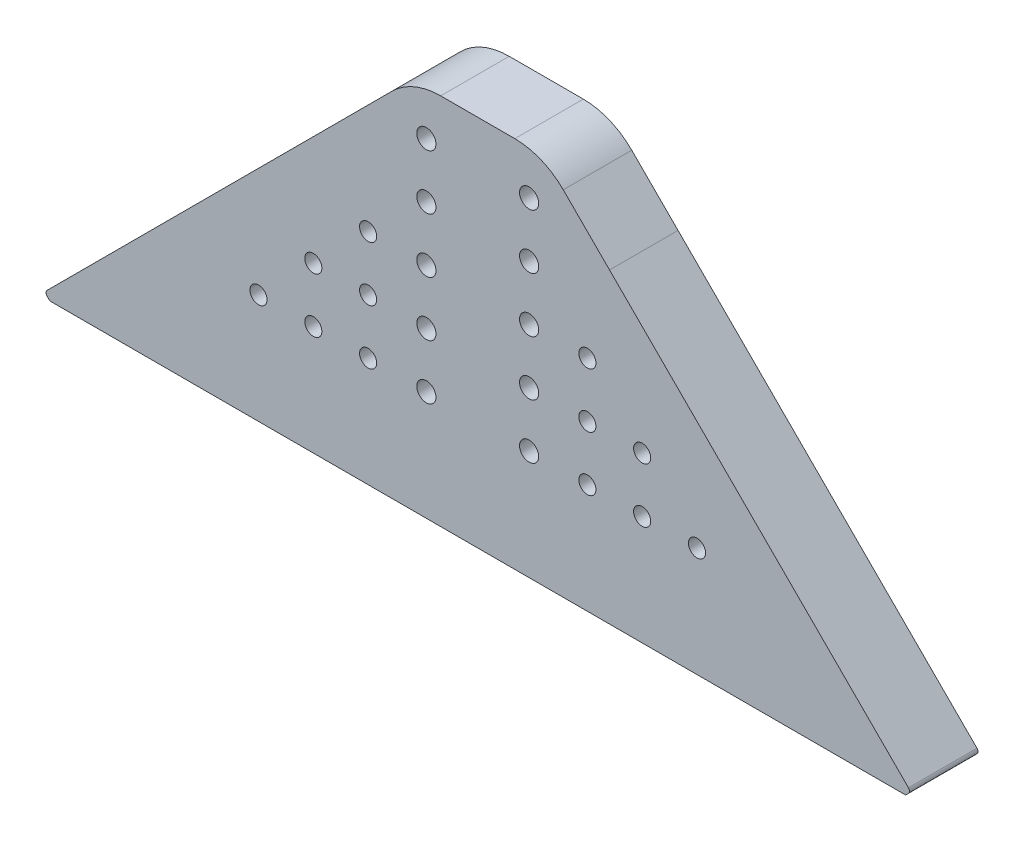
from build123d import *

# Parameters (mm, degrees)
SKETCH_3_R      = 1.25
SKETCH_3_R_2    = 1.4
EXTRUDE_2_DEPTH = 10


with BuildPart() as part:
    # 草图3 → 凸台-拉伸2 (new body)
    with BuildSketch(Plane.XY):
        with BuildLine():
            Line((1203.23159256, 480.404853327), (1082.731592366, 480.404853327))
            Line((1082.731592366, 480.404853327), (1082.310142824, 480.826300075))
            ThreePointArc((1082.310142824, 480.826300075), (1082.163698991, 481.179854306), (1082.310145601, 481.533406638))
            Line((1082.310145601, 481.533406638), (1132.702661596, 531.925922701))
            ThreePointArc((1132.702661596, 531.925922701), (1135.946895085, 534.093650218), (1139.773729412, 534.854854894))
            Line((1139.773729412, 534.854854894), (1150.589455978, 534.854854894))
            ThreePointArc((1150.589455978, 534.854854894), (1154.416289827, 534.093650416), (1157.660523063, 531.925923433))
            Line((1157.660523063, 531.925923433), (1164.418316344, 525.168131543))
            Line((1164.418316344, 525.168131543), (1208.053038819, 481.533406638))
            ThreePointArc((1208.053038819, 481.533406638), (1208.199485429, 481.179853247), (1208.053038819, 480.826299856))
            Line((1208.053038819, 480.826299856), (1207.631592536, 480.404853327))
            Line((1207.631592536, 480.404853327), (1203.23159256, 480.404853327))
        make_face()
        with Locations((1113.18159221, 496.404853247)):
            Circle(SKETCH_3_R, mode=Mode.SUBTRACT)
        with Locations((1121.18159221, 496.404853247)):
            Circle(SKETCH_3_R, mode=Mode.SUBTRACT)
        with Locations((1129.18159221, 512.404853247)):
            Circle(SKETCH_3_R, mode=Mode.SUBTRACT)
        with Locations((1129.18159221, 504.404853247)):
            Circle(SKETCH_3_R, mode=Mode.SUBTRACT)
        with Locations((1129.18159221, 496.404853247)):
            Circle(SKETCH_3_R, mode=Mode.SUBTRACT)
        with Locations((1121.18159221, 504.404853247)):
            Circle(SKETCH_3_R, mode=Mode.SUBTRACT)
        with Locations((1169.18159221, 504.404853247)):
            Circle(SKETCH_3_R, mode=Mode.SUBTRACT)
        with Locations((1161.18159221, 496.404853247)):
            Circle(SKETCH_3_R, mode=Mode.SUBTRACT)
        with Locations((1161.18159221, 504.404853247)):
            Circle(SKETCH_3_R, mode=Mode.SUBTRACT)
        with Locations((1161.18159221, 512.404853247)):
            Circle(SKETCH_3_R, mode=Mode.SUBTRACT)
        with Locations((1169.18159221, 496.404853247)):
            Circle(SKETCH_3_R, mode=Mode.SUBTRACT)
        with Locations((1177.18159221, 496.404853247)):
            Circle(SKETCH_3_R, mode=Mode.SUBTRACT)
        with Locations((1137.68159221, 496.404853166)):
            Circle(SKETCH_3_R_2, mode=Mode.SUBTRACT)
        with Locations((1152.68159221, 496.404853166)):
            Circle(SKETCH_3_R_2, mode=Mode.SUBTRACT)
        with Locations((1137.68159221, 504.404852614)):
            Circle(SKETCH_3_R_2, mode=Mode.SUBTRACT)
        with Locations((1152.68159221, 504.404852614)):
            Circle(SKETCH_3_R_2, mode=Mode.SUBTRACT)
        with Locations((1137.68159221, 512.404853926)):
            Circle(SKETCH_3_R_2, mode=Mode.SUBTRACT)
        with Locations((1152.68159221, 512.404853926)):
            Circle(SKETCH_3_R_2, mode=Mode.SUBTRACT)
        with Locations((1137.68159221, 520.404851512)):
            Circle(SKETCH_3_R_2, mode=Mode.SUBTRACT)
        with Locations((1152.68159221, 520.404851512)):
            Circle(SKETCH_3_R_2, mode=Mode.SUBTRACT)
        with Locations((1137.68159221, 528.404852823)):
            Circle(SKETCH_3_R_2, mode=Mode.SUBTRACT)
        with Locations((1152.68159221, 528.404852823)):
            Circle(SKETCH_3_R_2, mode=Mode.SUBTRACT)
    extrude(amount=EXTRUDE_2_DEPTH)


solid = part.part
